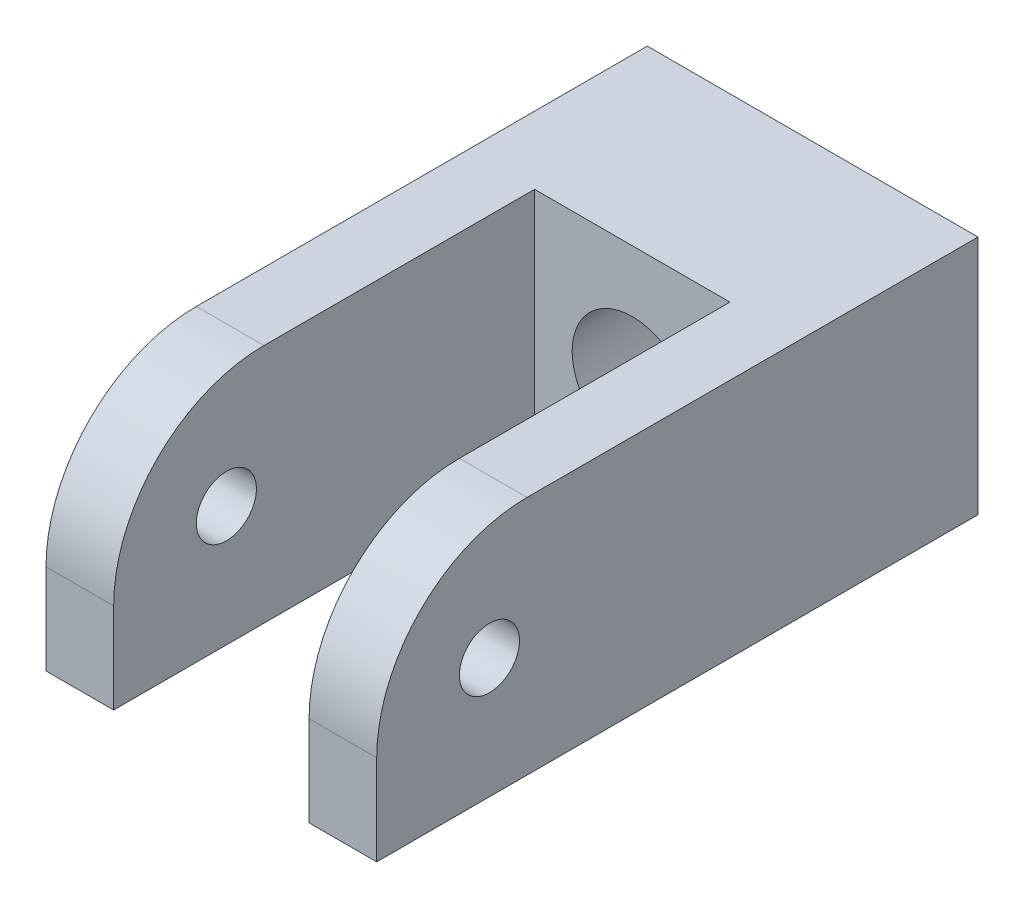
from build123d import *

# Parameters (mm, degrees)
BOSS_EXTRUDE1_DEPTH = 16
FILLET1_R           = 10
SKETCH2_R           = 4
CUT_EXTRUDE1_DEPTH  = 16
SKETCH3_R           = 2
CUT_EXTRUDE2_DEPTH  = 24


with BuildPart() as part:
    # Sketch1 → Boss-Extrude1 (new body)
    with BuildSketch(Plane(origin=(0, 0, 0), x_dir=(1, 0, 0), z_dir=(0, 1, 0))):
        Polygon((-11, 20), (-11, -20), (-6.5, -20), (-6.5, 8), (6.5, 8), (6.5, -20), (11, -20), (11, 20), align=None)
    extrude(amount=BOSS_EXTRUDE1_DEPTH)

    # Fillet1
    fillet1_edges = [part.edges().sort_by_distance(p)[0] for p in [
        (-8.75, 16, 20),
        (8.75, 16, 20),
    ]]
    fillet(fillet1_edges, radius=FILLET1_R)

    # Sketch2 → Cut-Extrude1 (cut)
    with BuildSketch(Plane(origin=(0, 0, -20), x_dir=(-1, 0, 0), z_dir=(0, 0, -1))):
        with Locations((0, 7.920875605)):
            Circle(SKETCH2_R)
    extrude(amount=-CUT_EXTRUDE1_DEPTH, mode=Mode.SUBTRACT)

    # Sketch3 → Cut-Extrude2 (cut)
    with BuildSketch(Plane.ZY.offset(11)):
        with Locations((12.5, 8)):
            Circle(SKETCH3_R)
    extrude(amount=-CUT_EXTRUDE2_DEPTH, mode=Mode.SUBTRACT)


solid = part.part
